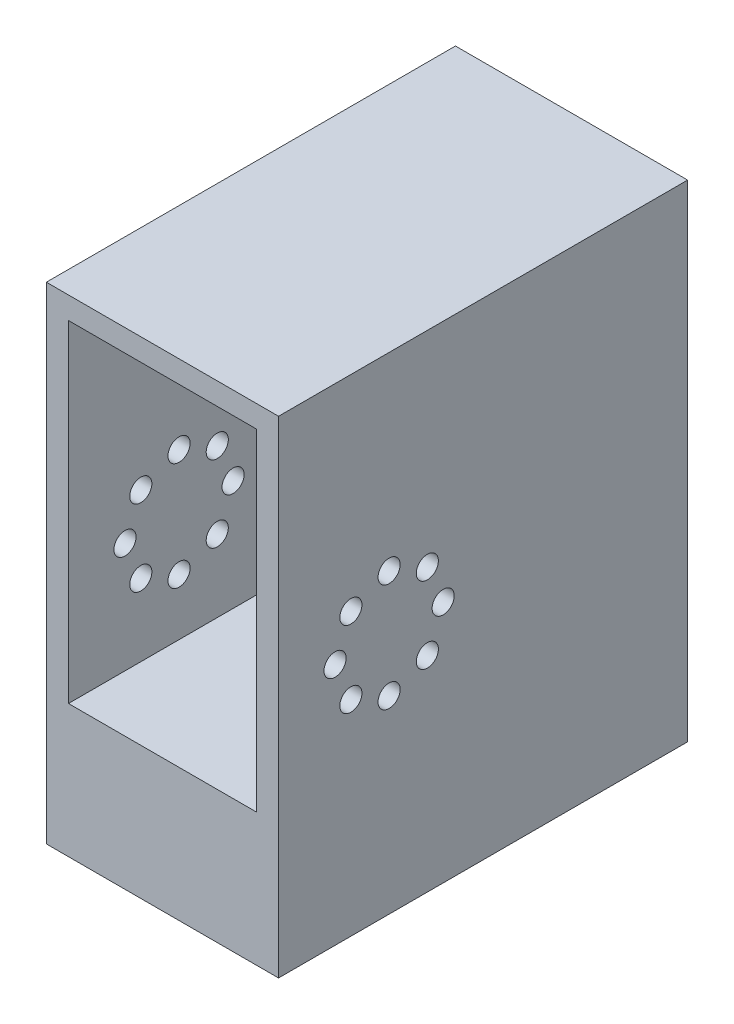
from build123d import *

# Parameters (mm, degrees)
CROQUIS1_W                 = 42
CROQUIS1_H                 = 68
CROQUIS1_W_2               = 34
CROQUIS1_H_2               = 60
SALIENTE_EXTRUIR1_DEPTH    = 60
CROQUIS2_R                 = 2
CORTAR_EXTRUIR1_DEPTH      = 39
CORTAR_EXTRUIR1_DEPTH_BACK = 5
CROQUIS3_W                 = 42
CROQUIS3_H                 = 68
SALIENTE_EXTRUIR2_DEPTH    = 4
CROQUIS4_W                 = 64
CROQUIS4_H                 = 20
SALIENTE_EXTRUIR3_DEPTH    = 42
CROQUIS5_W                 = 42
CROQUIS5_H                 = 88
SALIENTE_EXTRUIR4_DEPTH    = 10
CROQUIS6_R                 = 1.2
CORTAR_EXTRUIR2_DEPTH      = 10


with BuildPart() as part:
    # Croquis1 → Saliente-Extruir1 (new body)
    with BuildSketch(Plane.XY):
        Rectangle(CROQUIS1_W, CROQUIS1_H)
        Rectangle(CROQUIS1_W_2, CROQUIS1_H_2, mode=Mode.SUBTRACT)
    extrude(amount=SALIENTE_EXTRUIR1_DEPTH)

    # Croquis2 → Cortar-Extruir1 (cut, two sides)
    with BuildSketch(Plane(origin=(-17, 0, 0), x_dir=(0, 0, -1), z_dir=(1, 0, 0))) as cortar_extruir1_sk:
        with Locations((-49.779, -10)):
            Circle(CROQUIS2_R)
        with Locations((-46.914797213, -3.085202787)):
            Circle(CROQUIS2_R)
        with Locations((-40, -0.221)):
            Circle(CROQUIS2_R)
        with Locations((-33.085202787, -3.085202787)):
            Circle(CROQUIS2_R)
        with Locations((-30.221, -10)):
            Circle(CROQUIS2_R)
        with Locations((-33.085202787, -16.914797213)):
            Circle(CROQUIS2_R)
        with Locations((-40, -19.779)):
            Circle(CROQUIS2_R)
        with Locations((-46.914797213, -16.914797213)):
            Circle(CROQUIS2_R)
    extrude(amount=CORTAR_EXTRUIR1_DEPTH, mode=Mode.SUBTRACT)
    extrude(cortar_extruir1_sk.sketch, amount=-CORTAR_EXTRUIR1_DEPTH_BACK, mode=Mode.SUBTRACT)

    # Croquis3 → Saliente-Extruir2 (add)
    with BuildSketch(Plane(origin=(0, 0, 0), x_dir=(-1, 0, 0), z_dir=(0, 0, -1))):
        Rectangle(CROQUIS3_W, CROQUIS3_H)
    extrude(amount=SALIENTE_EXTRUIR2_DEPTH)

    # Croquis4 → Saliente-Extruir3 (add)
    with BuildSketch(Plane(origin=(21, 0, 0), x_dir=(0, 0, -1), z_dir=(1, 0, 0))):
        with Locations((-28, -44)):
            Rectangle(CROQUIS4_W, CROQUIS4_H)
    extrude(amount=-SALIENTE_EXTRUIR3_DEPTH)

    # Croquis5 → Saliente-Extruir4 (add)
    with BuildSketch(Plane(origin=(0, 0, -4), x_dir=(-1, 0, 0), z_dir=(0, 0, -1))):
        with Locations((0, -10)):
            Rectangle(CROQUIS5_W, CROQUIS5_H)
    extrude(amount=SALIENTE_EXTRUIR4_DEPTH)

    # Croquis6 → Cortar-Extruir2 (cut)
    with BuildSketch(Plane(origin=(0, 0, -14), x_dir=(-1, 0, 0), z_dir=(0, 0, -1))):
        with Locations((0, -3)):
            Circle(CROQUIS6_R)
        with Locations((0, 8.6)):
            Circle(CROQUIS6_R)
        with Locations((7, -10)):
            Circle(CROQUIS6_R)
        with Locations((0, -17)):
            Circle(CROQUIS6_R)
        with Locations((-7, -10)):
            Circle(CROQUIS6_R)
        with Locations((0, -28.6)):
            Circle(CROQUIS6_R)
    extrude(amount=-CORTAR_EXTRUIR2_DEPTH, mode=Mode.SUBTRACT)


solid = part.part
